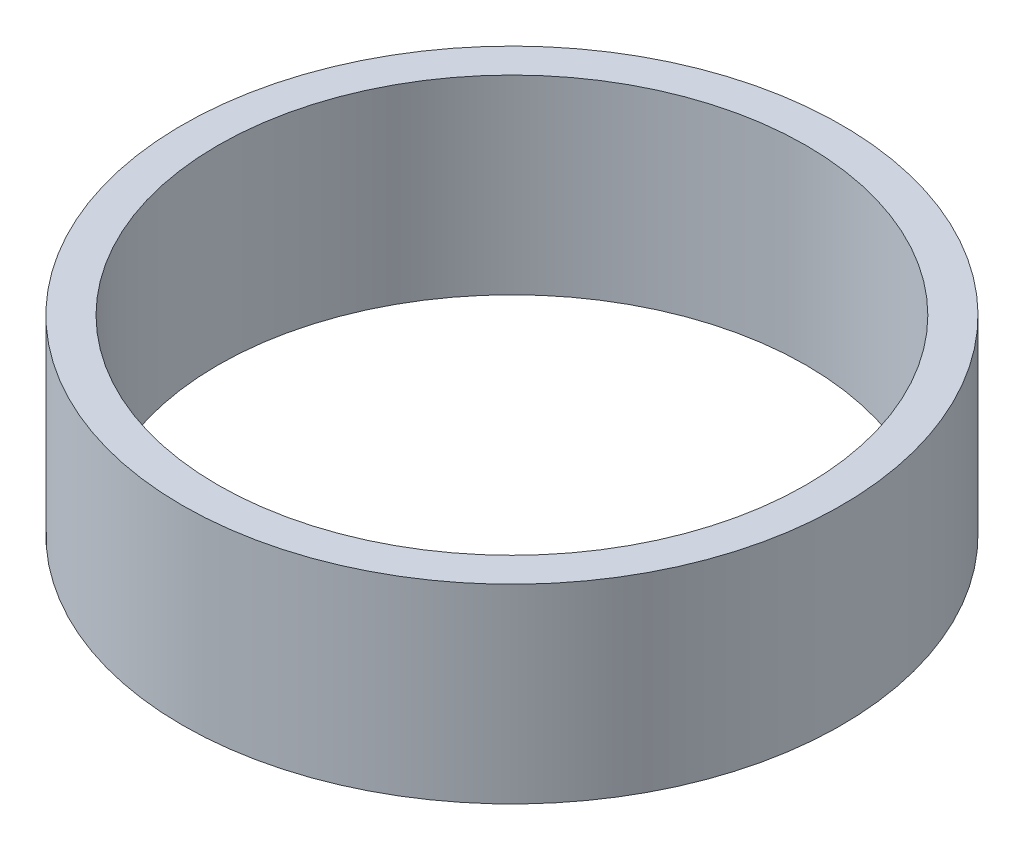
from build123d import *

# Parameters (mm, degrees)
SKETCH_1_R      = 19.05
SKETCH_1_R_2    = 17
EXTRUDE_1_DEPTH = 11


with BuildPart() as part:
    # 草图1 → 凸台-拉伸1 (new body)
    with BuildSketch(Plane(origin=(0, 0, 0), x_dir=(1, 0, 0), z_dir=(0, 1, 0))):
        with Locations(Location((0, 0, 0), (0, 0, 270))):  # turned: the seam where the file's is
            Circle(SKETCH_1_R)
        with Locations(Location((0, 0, 0), (0, 0, 270))):  # turned: the seam where the file's is
            Circle(SKETCH_1_R_2, mode=Mode.SUBTRACT)
    extrude(amount=EXTRUDE_1_DEPTH)


solid = part.part
